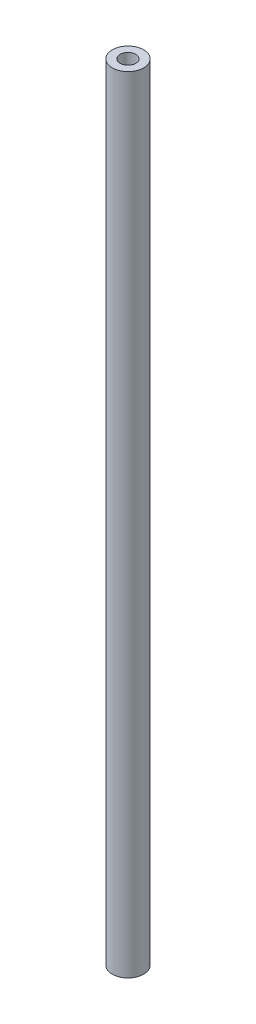
from build123d import *

# Parameters (mm, degrees)
SKETCH_1_R      = 2
SKETCH_1_R_2    = 1
EXTRUDE_1_DEPTH = 100


with BuildPart() as part:
    # Эскиз1 → Бобышка-Вытянуть1 (new body)
    with BuildSketch(Plane(origin=(0, 0, 0), x_dir=(1, 0, 0), z_dir=(0, 1, 0))):
        Circle(SKETCH_1_R)
        Circle(SKETCH_1_R_2, mode=Mode.SUBTRACT)
    extrude(amount=EXTRUDE_1_DEPTH)


solid = part.part
